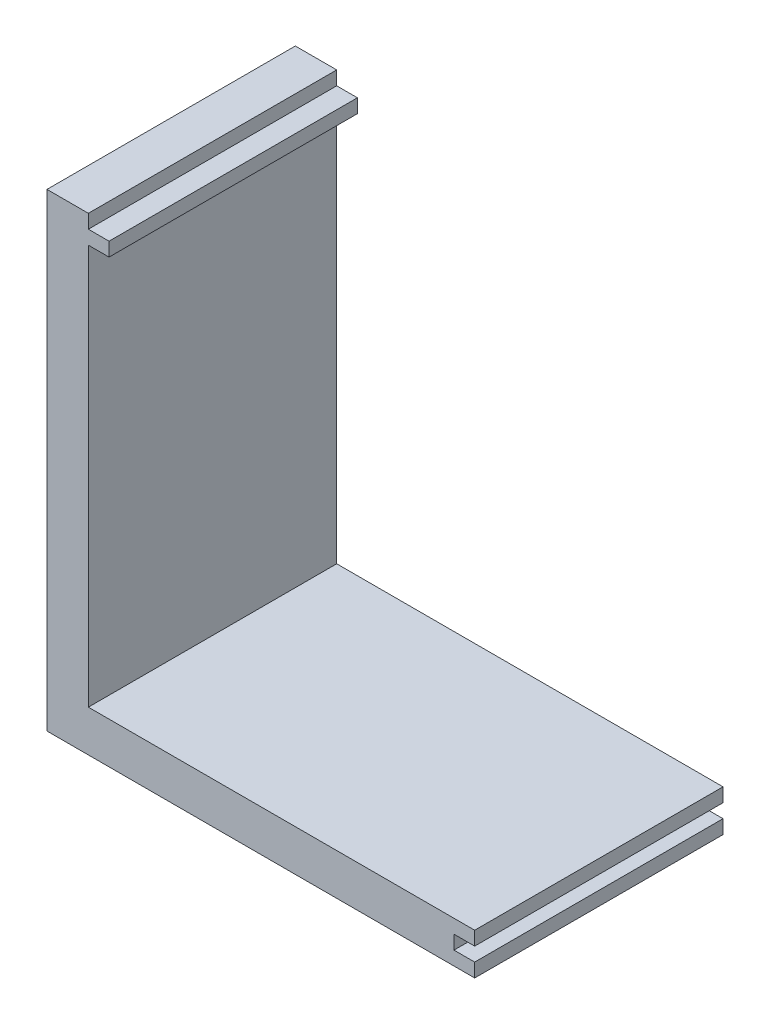
from build123d import *

# Parameters (mm, degrees)
BOSS_EXTRUDE_EQUERRE_DEPTH = 18
ESQUISSE2_W                = 3
ESQUISSE2_H                = 1
ENL_V_MAT_EXTRU_1_DEPTH    = 19
ESQUISSE3_W                = 1.5
ESQUISSE3_H                = 1
BOSS_EXTRU_1_DEPTH         = 18


with BuildPart() as part:
    # Esquisse1 → Boss_Extrude_Equerre (new body)
    with BuildSketch(Plane(origin=(0, 0, 0), x_dir=(0, 1, 0), z_dir=(0, 0, 1))):
        Polygon((0, 0), (31, 0), (31, 3), (-3, 3), (-3, 0), (-3, -28), (0, -28), align=None)
    extrude(amount=BOSS_EXTRUDE_EQUERRE_DEPTH)

    # Esquisse2 → Enlèv. mat.-Extru.1 (cut, through all)
    with BuildSketch(Plane.XY.offset(18)):
        with Locations((28, -1.5)):
            Rectangle(ESQUISSE2_W, ESQUISSE2_H)
    extrude(amount=-ENL_V_MAT_EXTRU_1_DEPTH, mode=Mode.SUBTRACT)

    # Esquisse3 → Boss.-Extru.1 (add, through all)
    with BuildSketch(Plane.XY.offset(18)):
        with Locations((0.75, 29.5)):
            Rectangle(ESQUISSE3_W, ESQUISSE3_H)
    extrude(amount=-BOSS_EXTRU_1_DEPTH)


solid = part.part
